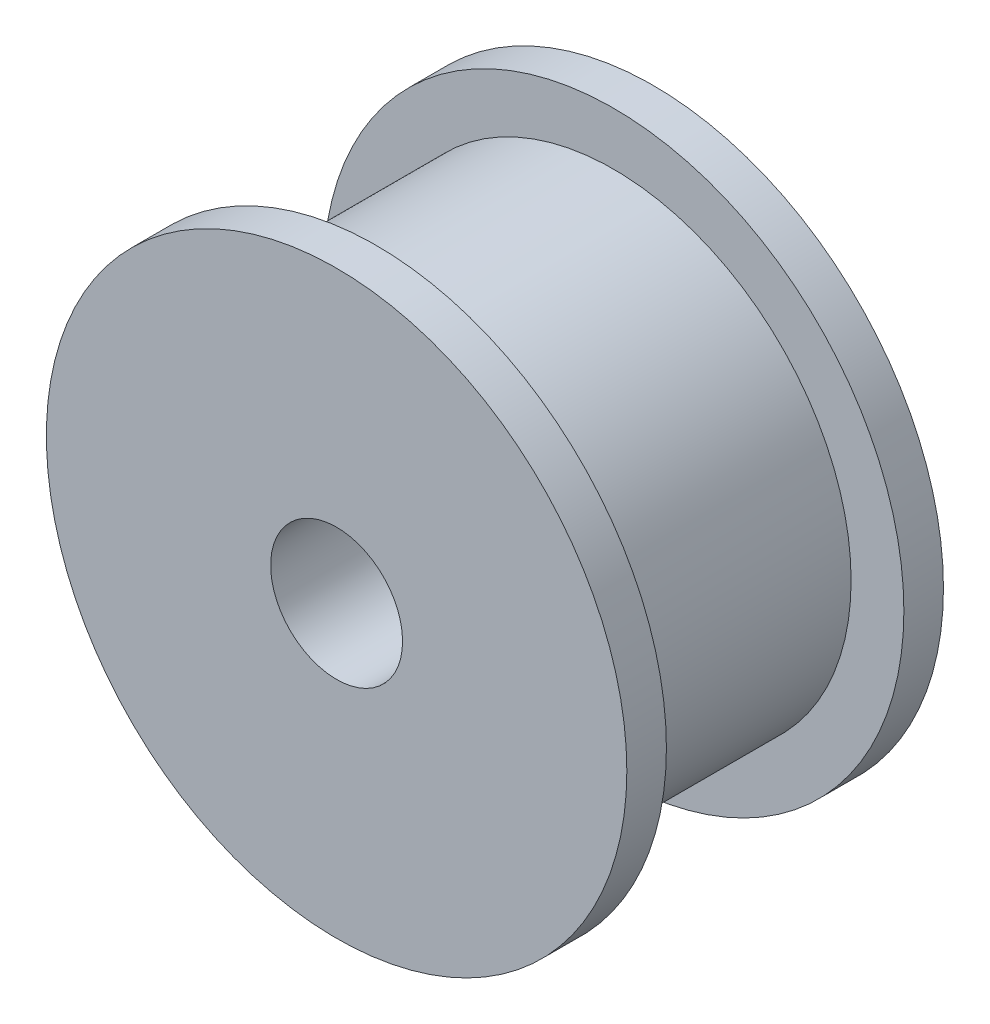
from build123d import *

# Parameters (mm, degrees)
ESQUISSE1_R                  = 11
BOSS_EXTRU_1_DEPTH           = 1.5
ESQUISSE2_R                  = 9
BOSS_EXTRU_2_DEPTH           = 9
ESQUISSE3_R                  = 11
BOSS_EXTRU_3_DEPTH           = 1.5
ESQUISSE4_R                  = 2.5
ENL_V_MAT_EXTRU_1_DEPTH      = 1
ENL_V_MAT_EXTRU_1_DEPTH_BACK = 13


with BuildPart() as part:
    # Esquisse1 → Boss.-Extru.1 (new body)
    with BuildSketch(Plane.XY):
        Circle(ESQUISSE1_R)
    extrude(amount=BOSS_EXTRU_1_DEPTH)

    # Esquisse2 → Boss.-Extru.2 (add)
    with BuildSketch(Plane.XY.offset(1.5)):
        Circle(ESQUISSE2_R)
    extrude(amount=BOSS_EXTRU_2_DEPTH)

    # Esquisse3 → Boss.-Extru.3 (add)
    with BuildSketch(Plane.XY.offset(10.5)):
        Circle(ESQUISSE3_R)
    extrude(amount=BOSS_EXTRU_3_DEPTH)

    # Esquisse4 → Enlèv. mat.-Extru.1 (cut, two sides)
    with BuildSketch(Plane.XY.offset(12)) as enl_v_mat_extru_1_sk:
        Circle(ESQUISSE4_R)
    extrude(amount=ENL_V_MAT_EXTRU_1_DEPTH, mode=Mode.SUBTRACT)
    extrude(enl_v_mat_extru_1_sk.sketch, amount=-ENL_V_MAT_EXTRU_1_DEPTH_BACK, mode=Mode.SUBTRACT)


solid = part.part
